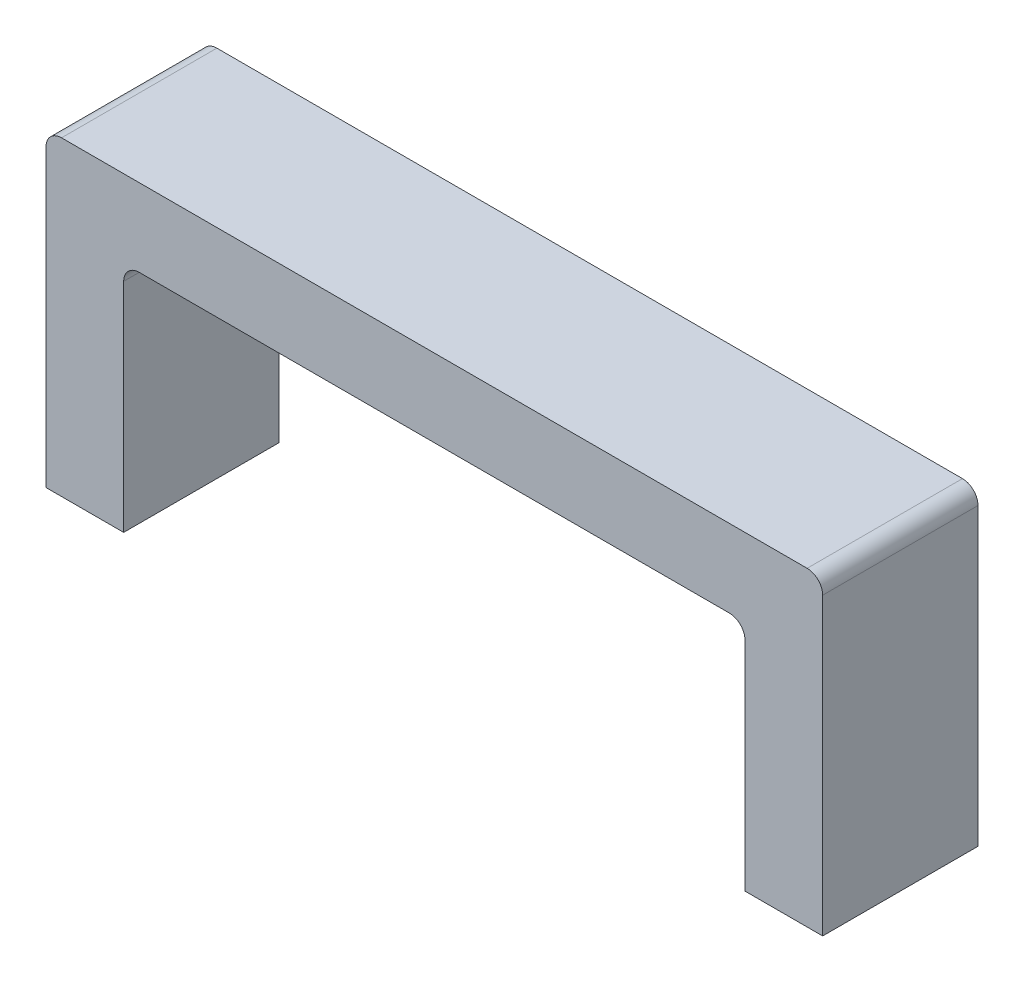
from build123d import *

# Parameters (mm, degrees)
BOSS_EXTRUDE1_DEPTH = 25.4


with BuildPart() as part:
    # Sketch1 → Boss-Extrude1 (new body)
    with BuildSketch(Plane.XY):
        with BuildLine():
            Line((0, 0), (0, 48.26))
            ThreePointArc((0, 48.26), (0.743948776, 50.056051224), (2.54, 50.8))
            Line((2.54, 50.8), (124.46, 50.8))
            ThreePointArc((124.46, 50.8), (126.256051224, 50.056051224), (127, 48.26))
            Line((127, 48.26), (127, 0))
            Line((127, 0), (114.3, 0))
            Line((114.3, 0), (114.3, 35.56))
            ThreePointArc((114.3, 35.56), (113.556051224, 37.356051224), (111.76, 38.1))
            Line((111.76, 38.1), (15.24, 38.1))
            ThreePointArc((15.24, 38.1), (13.443948776, 37.356051224), (12.7, 35.56))
            Line((12.7, 35.56), (12.7, 0))
            Line((12.7, 0), (0, 0))
        make_face()
    extrude(amount=BOSS_EXTRUDE1_DEPTH)


solid = part.part
